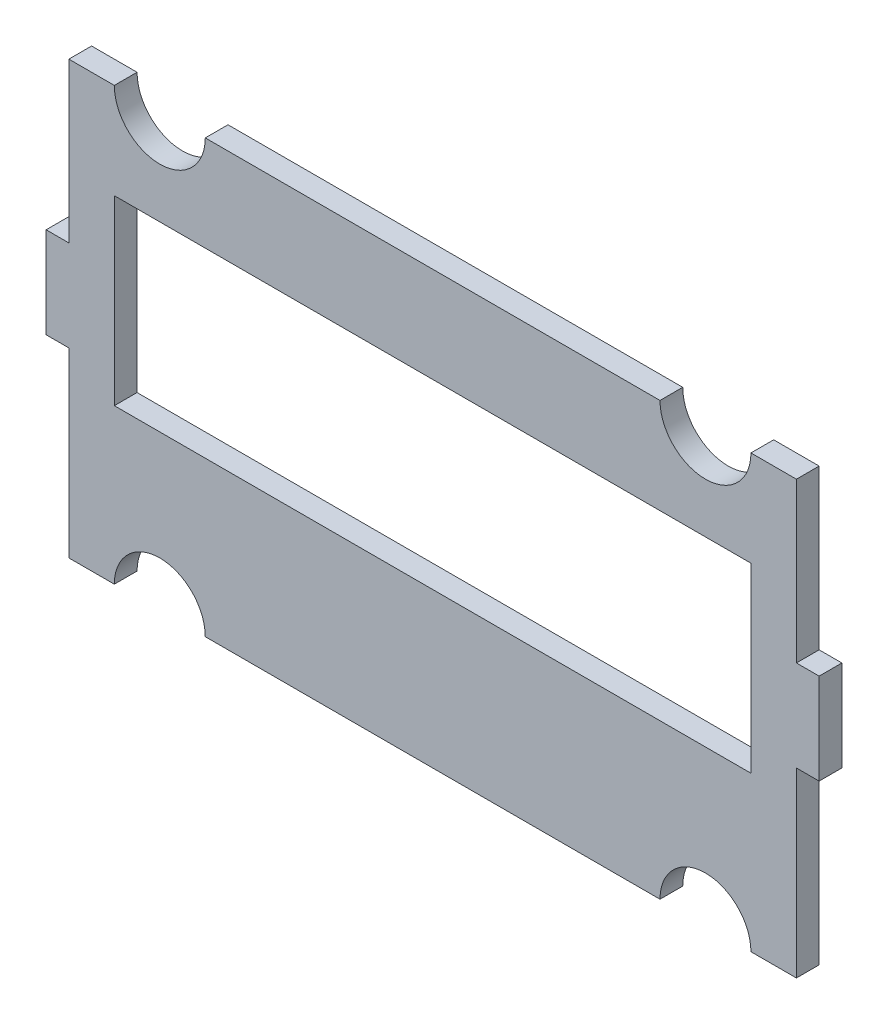
from build123d import *

# Parameters (mm, degrees)
SKETCH1_W           = 101.6
SKETCH1_H           = 63.5
BOSS_EXTRUDE1_DEPTH = 3.175
SKETCH2_W           = 88.9
SKETCH2_H           = 25.4
CUT_EXTRUDE1_DEPTH  = 4.175
SKETCH3_W           = 3.175
SKETCH3_H           = 12.7
BOSS_EXTRUDE2_DEPTH = 3.175
SKETCH4_W           = 101.6
SKETCH4_H           = 3.175
CUT_EXTRUDE2_DEPTH  = 4.175
CUT_EXTRUDE5_DEPTH  = 4.175


with BuildPart() as part:
    # Sketch1 → Boss-Extrude1 (new body)
    with BuildSketch(Plane.XY):
        with Locations((50.8, 31.75)):
            Rectangle(SKETCH1_W, SKETCH1_H)
    extrude(amount=BOSS_EXTRUDE1_DEPTH)

    # Sketch2 → Cut-Extrude1 (cut, through all)
    with BuildSketch(Plane.XY.offset(3.175)):
        with Locations((50.8, 34.29)):
            Rectangle(SKETCH2_W, SKETCH2_H)
    extrude(amount=-CUT_EXTRUDE1_DEPTH, mode=Mode.SUBTRACT)

    # Sketch3 → Boss-Extrude2 (add)
    with BuildSketch(Plane.XY.offset(3.175)):
        with Locations((-1.5875, 31.75)):
            Rectangle(SKETCH3_W, SKETCH3_H)
        with Locations((103.1875, 31.75)):
            Rectangle(SKETCH3_W, SKETCH3_H)
    extrude(amount=-BOSS_EXTRUDE2_DEPTH)

    # Sketch4 → Cut-Extrude2 (cut, through all)
    with BuildSketch(Plane.XY.offset(3.175)):
        with Locations((50.8, 61.9125)):
            Rectangle(SKETCH4_W, SKETCH4_H)
    extrude(amount=-CUT_EXTRUDE2_DEPTH, mode=Mode.SUBTRACT)

    # Sketch7 → Cut-Extrude5 (cut, through all)
    with BuildSketch(Plane.XY.offset(3.175)):
        with BuildLine():
            Line((6.35, 0), (19.05, 0))
            ThreePointArc((19.05, 0), (12.7, 6.35), (6.35, 0))
        make_face()
        with BuildLine():
            Line((95.25, 0), (82.55, 0))
            ThreePointArc((82.55, 0), (88.9, 6.35), (95.25, 0))
        make_face()
        with BuildLine():
            Line((6.35, 60.325), (19.05, 60.325))
            ThreePointArc((19.05, 60.325), (12.7, 53.975), (6.35, 60.325))
        make_face()
        with BuildLine():
            Line((95.25, 60.325), (82.55, 60.325))
            ThreePointArc((82.55, 60.325), (88.9, 53.975), (95.25, 60.325))
        make_face()
    extrude(amount=-CUT_EXTRUDE5_DEPTH, mode=Mode.SUBTRACT)


solid = part.part
